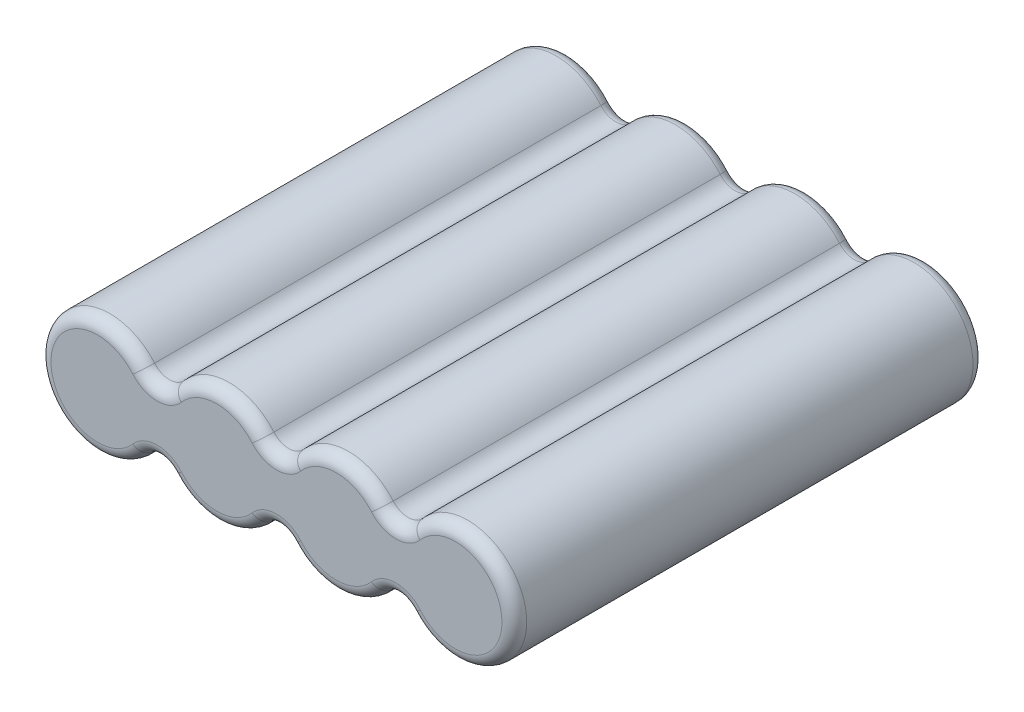
from build123d import *

# Parameters (mm, degrees)
BOSS_EXTRUDE1_DEPTH = 38.1
FILLET2_R           = 1


with BuildPart() as part:
    # Sketch1 → Boss-Extrude1 (new body)
    with BuildSketch(Plane.XY):
        with BuildLine():
            ThreePointArc((3.6195, 3.095258632), (-4.7625, 0), (3.6195, -3.095258632))
            ThreePointArc((3.6195, -3.095258632), (4.826, -2.53951151), (6.0325, -3.095258632))
            ThreePointArc((6.0325, -3.095258632), (9.652, -4.7625), (13.2715, -3.095258632))
            ThreePointArc((13.2715, -3.095258632), (14.478, -2.53951151), (15.6845, -3.095258632))
            ThreePointArc((15.6845, -3.095258632), (19.304, -4.7625), (22.9235, -3.095258632))
            ThreePointArc((22.9235, -3.095258632), (24.13, -2.53951151), (25.3365, -3.095258632))
            ThreePointArc((25.3365, -3.095258632), (33.7185, 0), (25.3365, 3.095258632))
            ThreePointArc((25.3365, 3.095258632), (24.13, 2.53951151), (22.9235, 3.095258632))
            ThreePointArc((22.9235, 3.095258632), (19.304, 4.7625), (15.6845, 3.095258632))
            ThreePointArc((15.6845, 3.095258632), (14.478, 2.53951151), (13.2715, 3.095258632))
            ThreePointArc((13.2715, 3.095258632), (9.652, 4.7625), (6.0325, 3.095258632))
            ThreePointArc((6.0325, 3.095258632), (4.826, 2.53951151), (3.6195, 3.095258632))
        make_face()
    extrude(amount=BOSS_EXTRUDE1_DEPTH)

    # Fillet2
    fillet2_edges = [part.edges().sort_by_distance(p)[0] for p in [
        (-4.7625, 0, 38.1),
        (14.478, 2.53951151, 0),
        (19.304, 4.7625, 0),
        (24.13, 2.53951151, 0),
        (33.7185, 0, 0),
        (24.13, -2.53951151, 0),
        (19.304, -4.7625, 0),
        (4.826, -2.53951151, 38.1),
        (14.478, -2.53951151, 0),
        (9.652, -4.7625, 0),
        (4.826, -2.53951151, 0),
        (-4.7625, 0, 0),
        (4.826, 2.53951151, 0),
        (9.652, 4.7625, 0),
        (9.652, -4.7625, 38.1),
        (14.478, -2.53951151, 38.1),
        (19.304, -4.7625, 38.1),
        (24.13, -2.53951151, 38.1),
        (33.7185, 0, 38.1),
        (24.13, 2.53951151, 38.1),
        (19.304, 4.7625, 38.1),
        (14.478, 2.53951151, 38.1),
        (9.652, 4.7625, 38.1),
        (4.826, 2.53951151, 38.1),
    ]]
    fillet(fillet2_edges, radius=FILLET2_R)


solid = part.part
